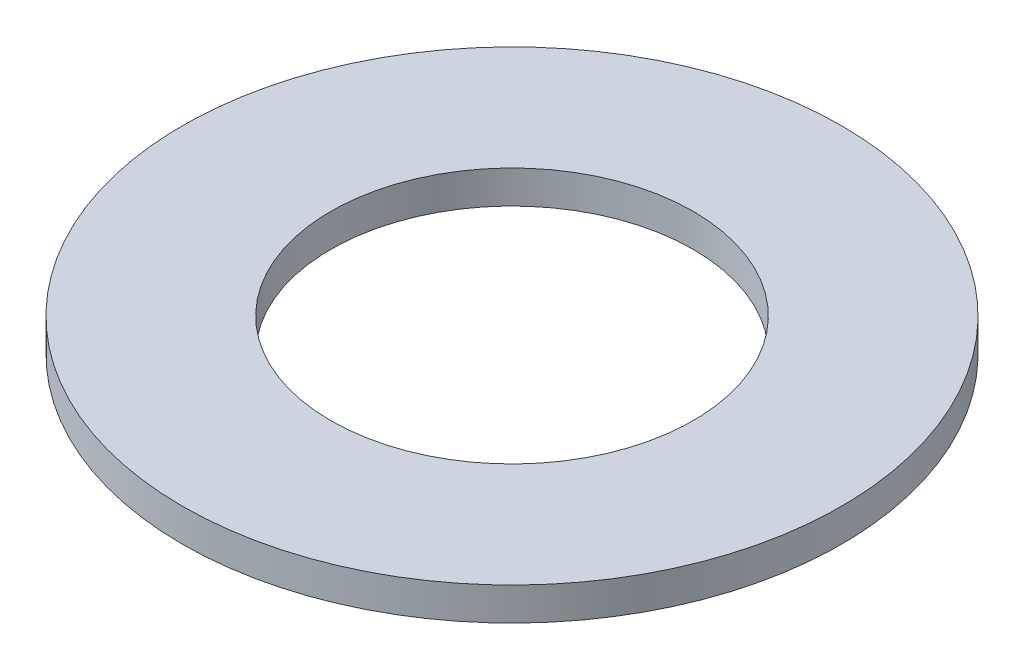
from build123d import *

# Parameters (mm, degrees)
CROQUIS1_R              = 10
CROQUIS1_R_2            = 5.5
SALIENTE_EXTRUIR1_DEPTH = 1


with BuildPart() as part:
    # Croquis1 → Saliente-Extruir1 (new body)
    with BuildSketch(Plane(origin=(0, 0, 0), x_dir=(1, 0, 0), z_dir=(0, 1, 0))):
        Circle(CROQUIS1_R)
        Circle(CROQUIS1_R_2, mode=Mode.SUBTRACT)
    extrude(amount=SALIENTE_EXTRUIR1_DEPTH)


solid = part.part
